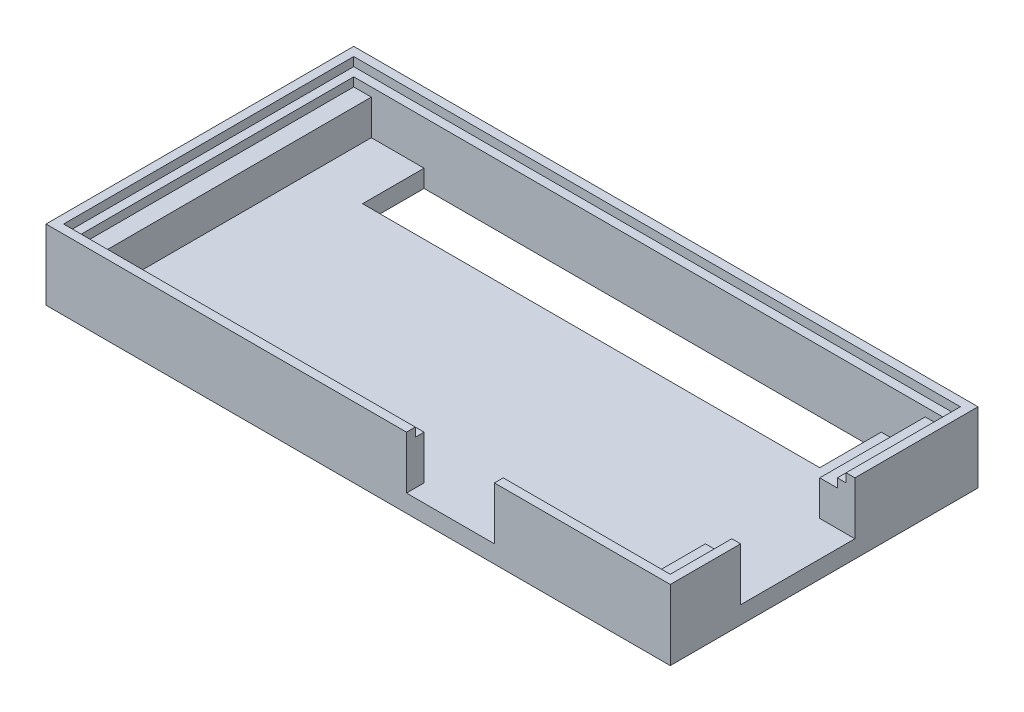
from build123d import *

# Parameters (mm, degrees)
SKETCH1_W           = 71
SKETCH1_H           = 35
BOSS_EXTRUDE1_DEPTH = 2
SKETCH2_W           = 71
SKETCH2_H           = 35
SKETCH2_W_2         = 67
SKETCH2_H_2         = 31
BOSS_EXTRUDE2_DEPTH = 5
SKETCH3_W           = 52
SKETCH3_H           = 7
CUT_EXTRUDE1_DEPTH  = 5
SKETCH4_W           = 2
SKETCH4_H           = 31
SKETCH4_H_2         = 12
SKETCH4_H_3         = 6
BOSS_EXTRUDE3_DEPTH = 4
SKETCH5_W           = 13
SKETCH5_H           = 5
CUT_EXTRUDE2_DEPTH  = 2
SKETCH6_W           = 10
SKETCH6_H           = 5
CUT_EXTRUDE3_DEPTH  = 2
BOSS_EXTRUDE4_DEPTH = 1


with BuildPart() as part:
    # Sketch1 → Boss-Extrude1 (new body)
    with BuildSketch(Plane(origin=(0, 0, 0), x_dir=(1, 0, 0), z_dir=(0, 1, 0))):
        with Locations((35.5, 17.5)):
            Rectangle(SKETCH1_W, SKETCH1_H)
    extrude(amount=BOSS_EXTRUDE1_DEPTH)

    # Sketch2 → Boss-Extrude2 (add)
    with BuildSketch(Plane(origin=(0, 2, 0), x_dir=(1, 0, 0), z_dir=(0, 1, 0))):
        with Locations((35.5, 17.5)):
            Rectangle(SKETCH2_W, SKETCH2_H)
        with Locations((35.5, 17.5)):
            Rectangle(SKETCH2_W_2, SKETCH2_H_2, mode=Mode.SUBTRACT)
    extrude(amount=BOSS_EXTRUDE2_DEPTH)

    # Sketch3 → Cut-Extrude1 (cut)
    with BuildSketch(Plane(origin=(0, 2, 0), x_dir=(1, 0, 0), z_dir=(0, 1, 0))):
        with Locations((36, 29.5)):
            Rectangle(SKETCH3_W, SKETCH3_H)
    extrude(amount=-CUT_EXTRUDE1_DEPTH, mode=Mode.SUBTRACT)

    # Sketch4 → Boss-Extrude3 (add)
    with BuildSketch(Plane(origin=(0, 2, 0), x_dir=(1, 0, 0), z_dir=(0, 1, 0))):
        with Locations((3, 17.5)):
            Rectangle(SKETCH4_W, SKETCH4_H)
        with Locations((68, 27)):
            Rectangle(SKETCH4_W, SKETCH4_H_2)
        with Locations((68, 5)):
            Rectangle(SKETCH4_W, SKETCH4_H_3)
    extrude(amount=BOSS_EXTRUDE3_DEPTH)

    # Sketch5 → Cut-Extrude2 (cut)
    with BuildSketch(Plane.ZY.offset(-69)):
        with Locations((-14.5, 4.5)):
            Rectangle(SKETCH5_W, SKETCH5_H)
    extrude(amount=-CUT_EXTRUDE2_DEPTH, mode=Mode.SUBTRACT)

    # Sketch6 → Cut-Extrude3 (cut)
    with BuildSketch(Plane(origin=(0, 0, -2), x_dir=(-1, 0, 0), z_dir=(0, 0, -1))):
        with Locations((-46, 4.5)):
            Rectangle(SKETCH6_W, SKETCH6_H)
    extrude(amount=-CUT_EXTRUDE3_DEPTH, mode=Mode.SUBTRACT)

    # Sketch7 → Boss-Extrude4 (add)
    with BuildSketch(Plane(origin=(0, 7, 0), x_dir=(1, 0, 0), z_dir=(0, 1, 0))):
        Polygon((71, 35), (0, 35), (0, 0), (41, 0), (41, 1), (1, 1), (1, 34), (70, 34), (70, 21), (71, 21), align=None)
        Polygon((51, 0), (71, 0), (71, 8), (70, 8), (70, 1), (51, 1), align=None)
    extrude(amount=BOSS_EXTRUDE4_DEPTH)


solid = part.part
